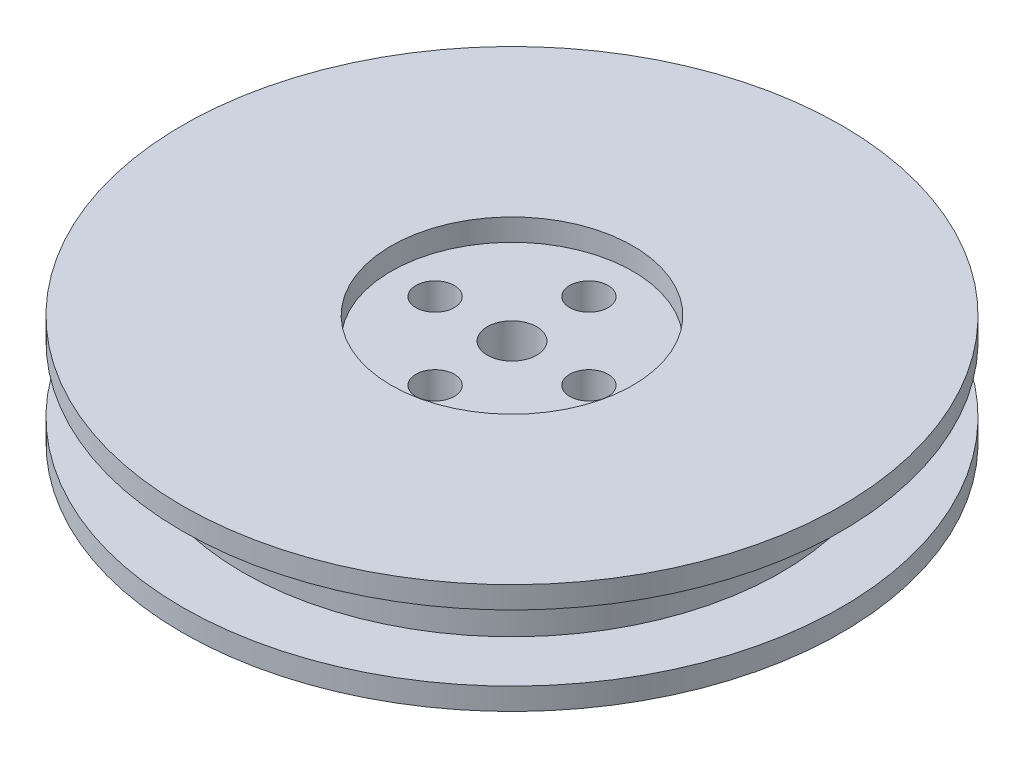
from build123d import *

# Parameters (mm, degrees)
SKETCH1_R           = 30
BOSS_EXTRUDE1_DEPTH = 2
SKETCH2_R           = 24.5
BOSS_EXTRUDE2_DEPTH = 6
SKETCH3_R           = 30
BOSS_EXTRUDE3_DEPTH = 2
SKETCH4_R           = 11
SKETCH4_R_2         = 2.25
CUT_EXTRUDE1_DEPTH  = 2
SKETCH5_R           = 2.25
CUT_EXTRUDE2_DEPTH  = 27
SKETCH6_R           = 1.75
CUT_EXTRUDE3_DEPTH  = 27
SKETCH7_R           = 11
CUT_EXTRUDE4_DEPTH  = 2


with BuildPart() as part:
    # Sketch1 → Boss-Extrude1 (new body)
    with BuildSketch(Plane(origin=(0, 0, 0), x_dir=(1, 0, 0), z_dir=(0, 1, 0))):
        Circle(SKETCH1_R)
    extrude(amount=BOSS_EXTRUDE1_DEPTH)

    # Sketch2 → Boss-Extrude2 (add)
    with BuildSketch(Plane(origin=(0, 2, 0), x_dir=(1, 0, 0), z_dir=(0, 1, 0))):
        Circle(SKETCH2_R)
    extrude(amount=BOSS_EXTRUDE2_DEPTH)

    # Sketch3 → Boss-Extrude3 (add)
    with BuildSketch(Plane(origin=(0, 8, 0), x_dir=(1, 0, 0), z_dir=(0, 1, 0))):
        Circle(SKETCH3_R)
    extrude(amount=BOSS_EXTRUDE3_DEPTH)

    # Sketch4 → Cut-Extrude1 (cut)
    with BuildSketch(Plane(origin=(0, 10, 0), x_dir=(1, 0, 0), z_dir=(0, 1, 0))):
        Circle(SKETCH4_R)
        Circle(SKETCH4_R_2, mode=Mode.SUBTRACT)
    extrude(amount=-CUT_EXTRUDE1_DEPTH, mode=Mode.SUBTRACT)

    # Sketch5 → Cut-Extrude2 (cut)
    with BuildSketch(Plane(origin=(0, 10, 0), x_dir=(1, 0, 0), z_dir=(0, 1, 0))):
        Circle(SKETCH5_R)
    extrude(amount=-CUT_EXTRUDE2_DEPTH, mode=Mode.SUBTRACT)

    # Sketch6 → Cut-Extrude3 (cut)
    with BuildSketch(Plane(origin=(0, 8, 0), x_dir=(1, 0, 0), z_dir=(0, 1, 0))):
        with Locations((0, 7)):
            Circle(SKETCH6_R)
        with Locations((7, 0)):
            Circle(SKETCH6_R)
        with Locations((0, -7)):
            Circle(SKETCH6_R)
        with Locations((-7, 0)):
            Circle(SKETCH6_R)
    extrude(amount=-CUT_EXTRUDE3_DEPTH, mode=Mode.SUBTRACT)

    # Sketch7 → Cut-Extrude4 (cut)
    with BuildSketch(Plane.XZ):
        Circle(SKETCH7_R)
    extrude(amount=-CUT_EXTRUDE4_DEPTH, mode=Mode.SUBTRACT)


solid = part.part
